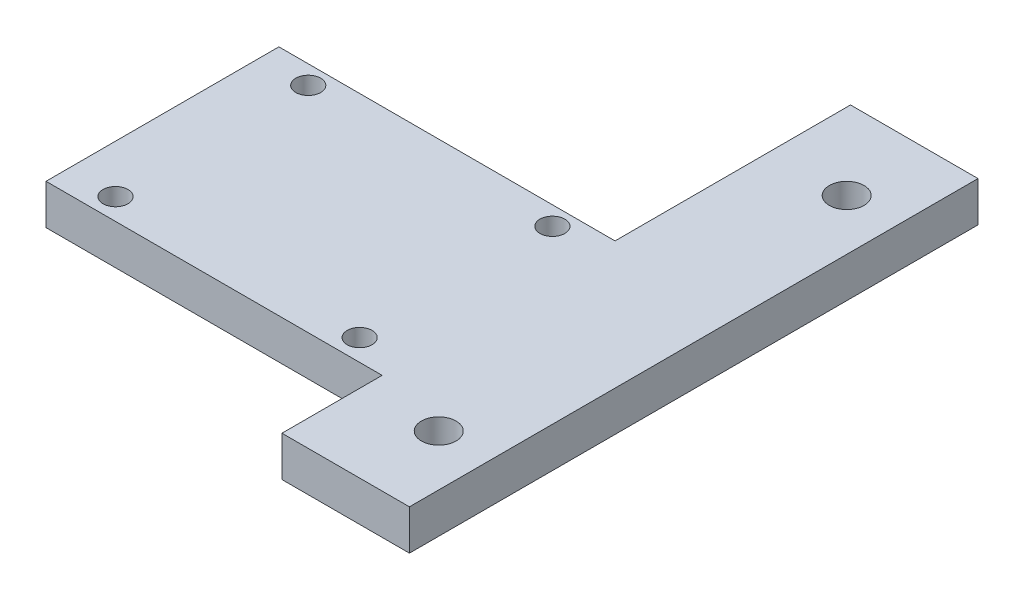
from build123d import *

# Parameters (mm, degrees)
SKETCH1_R           = 2.159
SKETCH1_R_2         = 1.55
BOSS_EXTRUDE1_DEPTH = 5


with BuildPart() as part:
    # Sketch1 → Boss-Extrude1 (new body)
    with BuildSketch(Plane(origin=(0, 0, 0), x_dir=(1, 0, 0), z_dir=(0, 1, 0))):
        Polygon((36.55, 27.14922), (36.55, -43.65078), (20.675, -43.65078), (20.675, -31.173955128), (-21.18269604, -31.173955128), (-21.18269604, -2.173955128), (20.675, -2.173955128), (20.675, 27.14922), align=None)
        with Locations((30.2, -33.65078)):
            Circle(SKETCH1_R, mode=Mode.SUBTRACT)
        with Locations((-15.2, -28.50156)):
            Circle(SKETCH1_R_2, mode=Mode.SUBTRACT)
        with Locations((15.19999, -28.50156)):
            Circle(SKETCH1_R_2, mode=Mode.SUBTRACT)
        with Locations((-15.2, -4.50156)):
            Circle(SKETCH1_R_2, mode=Mode.SUBTRACT)
        with Locations((15.2, -4.50156)):
            Circle(SKETCH1_R_2, mode=Mode.SUBTRACT)
        with Locations((30.2, 17.14922)):
            Circle(SKETCH1_R, mode=Mode.SUBTRACT)
    extrude(amount=BOSS_EXTRUDE1_DEPTH)


solid = part.part
